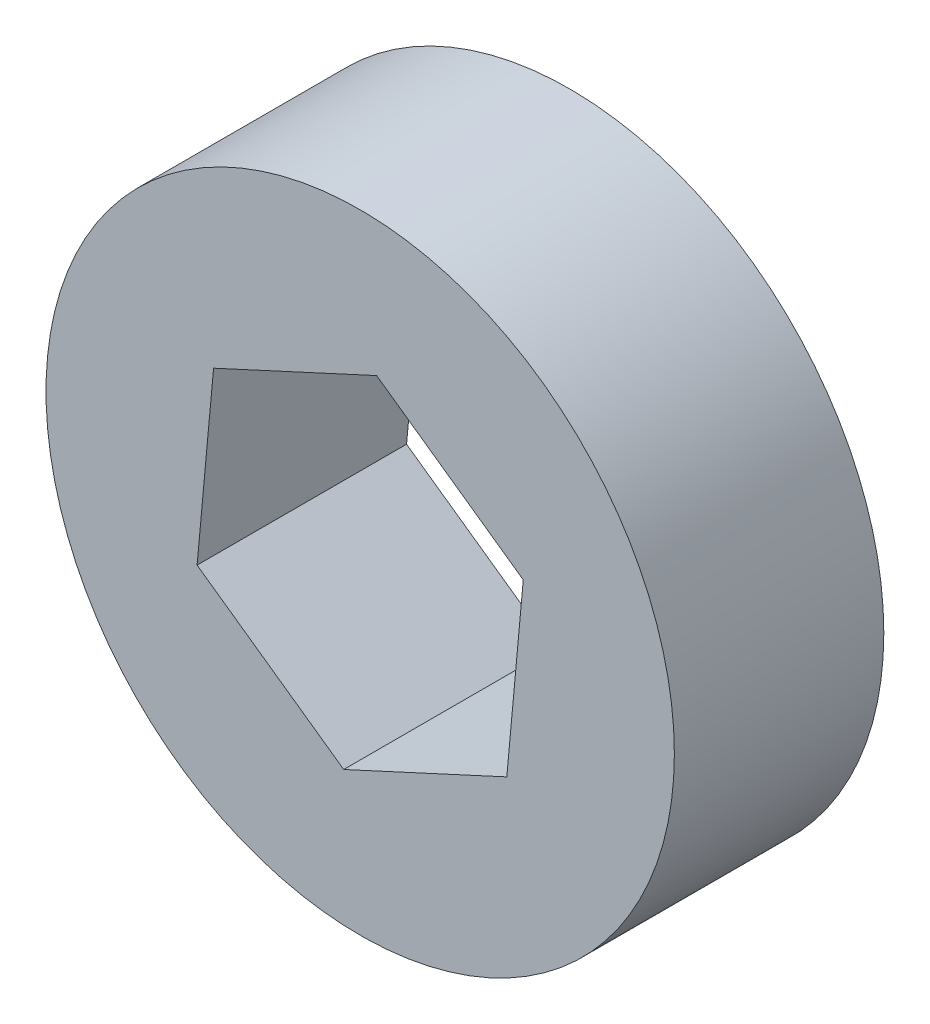
from build123d import *

# Parameters (mm, degrees)
ESQUISSE1_R        = 7.5
BOSS_EXTRU_1_DEPTH = 5


with BuildPart() as part:
    # Esquisse1 → Boss.-Extru.1 (new body)
    with BuildSketch(Plane.XY):
        Circle(ESQUISSE1_R)
        Polygon((0.393185127, 4.268457423), (-3.5, 2.47473702), (-3.893185127, -1.793720403), (-0.393185127, -4.268457423), (3.5, -2.47473702), (3.893185127, 1.793720403), align=None, mode=Mode.SUBTRACT)
    extrude(amount=BOSS_EXTRU_1_DEPTH)


solid = part.part
